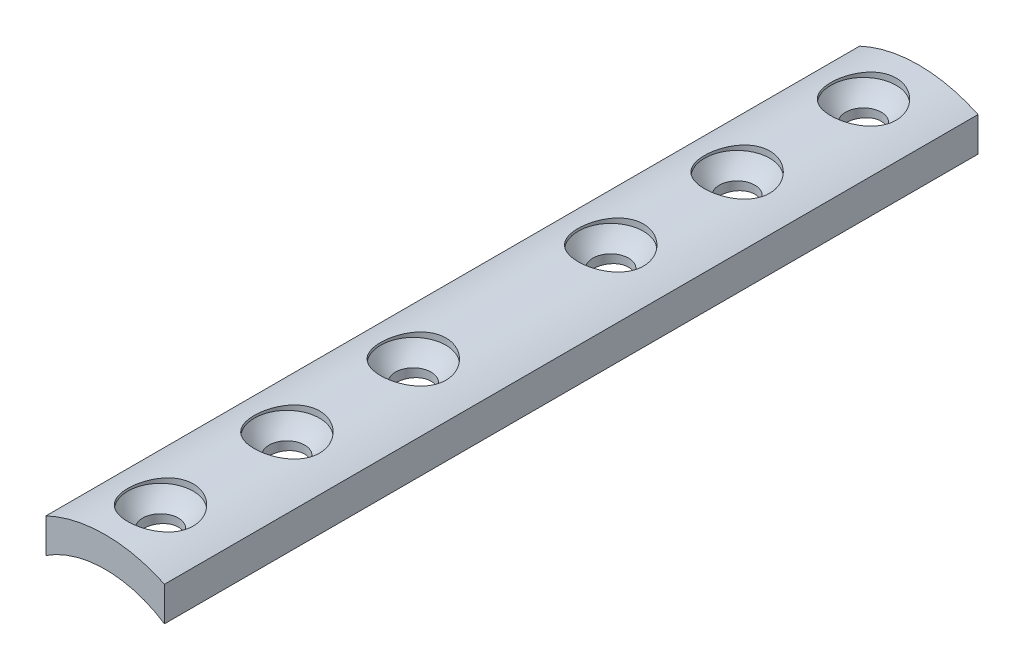
from build123d import *

# Parameters (mm, degrees)
BOSS_EXTRUDE1_DEPTH = 103
CUT_EXTRUDE2_START  = 6.04
SKETCH2_R           = 2.25
CUT_EXTRUDE2_DEPTH  = 11


with BuildPart() as part:
    # Sketch1 → Boss-Extrude1 (new body)
    with BuildSketch(Plane.XY):
        with BuildLine():
            Line((-7.5, 4.346659782), (-7.5, 0))
            ThreePointArc((-7.5, 0), (0, 2.235271482), (7.5, 0))
            Line((7.5, 0), (7.5, 4.346659782))
            ThreePointArc((7.5, 4.346659782), (0, 6.035271482), (-7.5, 4.346659782))
        make_face()
    extrude(amount=-BOSS_EXTRUDE1_DEPTH)

    # Sketch2 → Cut-Extrude2 (cut)
    with BuildSketch(Plane(origin=(0, 0, 0), x_dir=(1, 0, 0), z_dir=(0, 1, 0)).offset(CUT_EXTRUDE2_START)):
        with Locations((0, 96)):
            Circle(SKETCH2_R)
        with Locations((0, 80)):
            Circle(SKETCH2_R)
        with Locations((0, 64)):
            Circle(SKETCH2_R)
        with Locations((0, 39)):
            Circle(SKETCH2_R)
        with Locations((0, 23)):
            Circle(SKETCH2_R)
        with Locations((0, 7)):
            Circle(SKETCH2_R)
    extrude(amount=-CUT_EXTRUDE2_DEPTH, mode=Mode.SUBTRACT)

    # Sketch3 → Cut-Revolve1 (revolve, cut)
    with BuildSketch(Plane(origin=(0, 0, 0), x_dir=(0, 0, -1), z_dir=(1, 0, 0))):
        with BuildLine():
            Line((7, 3.235271482), (7, 6.035271482))
            Line((7, 6.035271482), (2.862670642, 6.035271482))
            Line((2.862670642, 6.035271482), (2.862670642, 5.235271482))
            ThreePointArc((2.862670642, 5.235271482), (3.707158189, 4.141681525), (4.75, 3.235271482))
            Line((4.75, 3.235271482), (7, 3.235271482))
        make_face()
    revolve(axis=Axis((0, 0, -7), (0, 1, 0)), mode=Mode.SUBTRACT)

    # Sketch3_3 → Cut-Revolve2 (revolve, cut)
    with BuildSketch(Plane(origin=(0, 0, 0), x_dir=(0, 0, -1), z_dir=(1, 0, 0))):
        with BuildLine():
            Line((23, 3.235271482), (23, 6.035271482))
            Line((23, 6.035271482), (18.862670642, 6.035271482))
            Line((18.862670642, 6.035271482), (18.862670642, 5.235271482))
            ThreePointArc((18.862670642, 5.235271482), (19.707158189, 4.141681525), (20.75, 3.235271482))
            Line((20.75, 3.235271482), (23, 3.235271482))
        make_face()
    revolve(axis=Axis((0, 5.890025873, -23), (0, -1, 0)), mode=Mode.SUBTRACT)

    # Sketch3_4 → Cut-Revolve3 (revolve, cut)
    with BuildSketch(Plane(origin=(0, 0, 0), x_dir=(0, 0, -1), z_dir=(1, 0, 0))):
        with BuildLine():
            Line((39, 3.235271482), (39, 6.035271482))
            Line((39, 6.035271482), (34.862670642, 6.035271482))
            Line((34.862670642, 6.035271482), (34.862670642, 5.235271482))
            ThreePointArc((34.862670642, 5.235271482), (35.707158189, 4.141681525), (36.75, 3.235271482))
            Line((36.75, 3.235271482), (39, 3.235271482))
        make_face()
    revolve(axis=Axis((0, 5.890025873, -39), (0, -1, 0)), mode=Mode.SUBTRACT)

    # Sketch3_5 → Cut-Revolve4 (revolve, cut)
    with BuildSketch(Plane(origin=(0, 0, 0), x_dir=(0, 0, -1), z_dir=(1, 0, 0))):
        with BuildLine():
            Line((64, 3.235271482), (64, 6.035271482))
            Line((64, 6.035271482), (59.862670642, 6.035271482))
            Line((59.862670642, 6.035271482), (59.862670642, 5.235271482))
            ThreePointArc((59.862670642, 5.235271482), (60.707158189, 4.141681525), (61.75, 3.235271482))
            Line((61.75, 3.235271482), (64, 3.235271482))
        make_face()
    revolve(axis=Axis((0, 5.890025873, -64), (0, -1, 0)), mode=Mode.SUBTRACT)

    # Sketch3_6 → Cut-Revolve5 (revolve, cut)
    with BuildSketch(Plane(origin=(0, 0, 0), x_dir=(0, 0, -1), z_dir=(1, 0, 0))):
        with BuildLine():
            Line((80, 3.235271482), (80, 6.035271482))
            Line((80, 6.035271482), (75.862670642, 6.035271482))
            Line((75.862670642, 6.035271482), (75.862670642, 5.235271482))
            ThreePointArc((75.862670642, 5.235271482), (76.707158189, 4.141681525), (77.75, 3.235271482))
            Line((77.75, 3.235271482), (80, 3.235271482))
        make_face()
    revolve(axis=Axis((0, 5.890025873, -80), (0, -1, 0)), mode=Mode.SUBTRACT)

    # Sketch3_7 → Cut-Revolve6 (revolve, cut)
    with BuildSketch(Plane(origin=(0, 0, 0), x_dir=(0, 0, -1), z_dir=(1, 0, 0))):
        with BuildLine():
            Line((96, 3.235271482), (96, 6.035271482))
            Line((96, 6.035271482), (91.862670642, 6.035271482))
            Line((91.862670642, 6.035271482), (91.862670642, 5.235271482))
            ThreePointArc((91.862670642, 5.235271482), (92.707158189, 4.141681525), (93.75, 3.235271482))
            Line((93.75, 3.235271482), (96, 3.235271482))
        make_face()
    revolve(axis=Axis((0, 5.890025873, -96), (0, -1, 0)), mode=Mode.SUBTRACT)


solid = part.part
